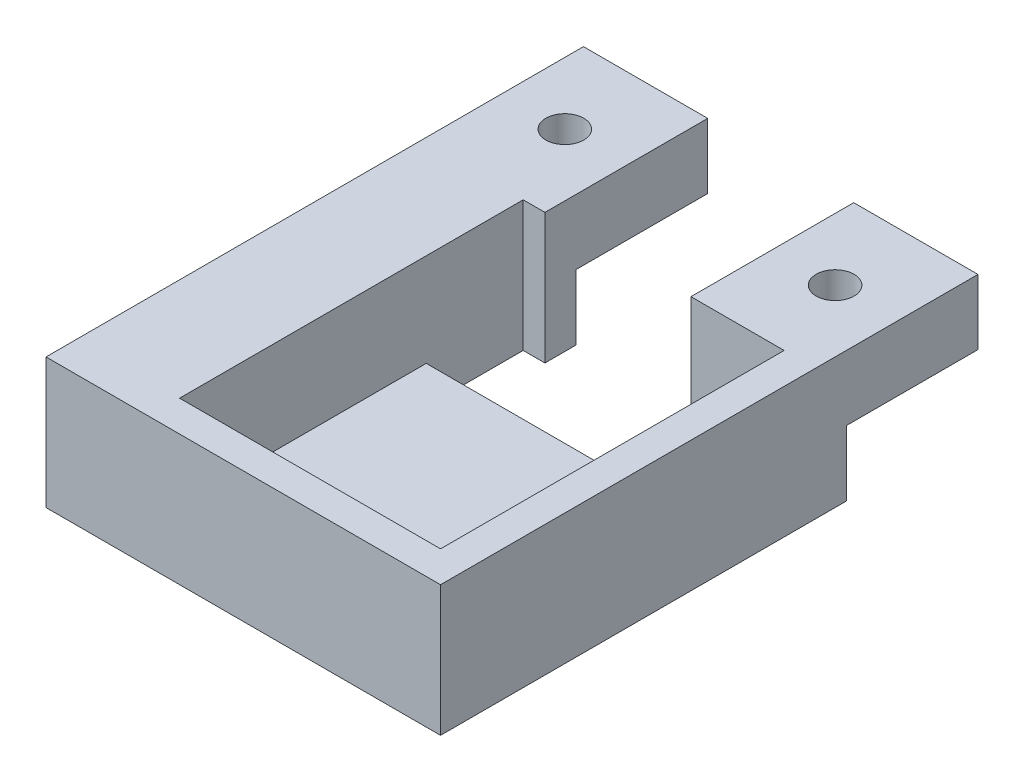
from build123d import *

# Parameters (mm, degrees)
BOSS_EXTRUDE1_DEPTH = 6
BOSS_EXTRUDE2_DEPTH = 21
BOSS_EXTRUDE3_START = 21
SKETCH1_6_W         = 20
SKETCH1_6_H         = 21.2
SKETCH1_6_R         = 3.05
BOSS_EXTRUDE3_DEPTH = 10.48


with BuildPart() as part:
    # Sketch1 → Boss-Extrude1 (new body)
    with BuildSketch(Plane(origin=(0, 0, 0), x_dir=(1, 0, 0), z_dir=(0, 1, 0))):
        Polygon((-37.5, 40.45), (-37.5, -24.85), (26, -24.85), (26, 40.45), (6, 40.45), (6, 35.45), (21, 35.45), (21, 19.85), (-21, 19.85), (-21, 35.45), (-17.5, 35.45), (-17.5, 40.45), align=None)
    extrude(amount=BOSS_EXTRUDE1_DEPTH)

    # Sketch1_5 → Boss-Extrude2 (add)
    with BuildSketch(Plane(origin=(0, 0, 0), x_dir=(1, 0, 0), z_dir=(0, 1, 0))):
        Polygon((-37.5, 40.45), (-37.5, -24.85), (26, -24.85), (26, 40.45), (6, 40.45), (6, 35.45), (21, 35.45), (21, 19.85), (21, -19.85), (-21, -19.85), (-21, 19.85), (-21, 35.45), (-17.5, 35.45), (-17.5, 40.45), align=None)
    extrude(amount=BOSS_EXTRUDE2_DEPTH)

    # Sketch1_6 → Boss-Extrude3 (add)
    with BuildSketch(Plane(origin=(0, 0, 0), x_dir=(1, 0, 0), z_dir=(0, 1, 0)).offset(BOSS_EXTRUDE3_START)):
        with Locations((-27.5, 51.05)):
            Rectangle(SKETCH1_6_W, SKETCH1_6_H)
        with Locations(Location((-27.5, 48.65, 0), (0, 0, 270))):
            Circle(SKETCH1_6_R, mode=Mode.SUBTRACT)
        with Locations((16, 51.05)):
            Rectangle(SKETCH1_6_W, SKETCH1_6_H)
        with Locations(Location((16, 48.65, 0), (0, 0, 270))):
            Circle(SKETCH1_6_R, mode=Mode.SUBTRACT)
    extrude(amount=-BOSS_EXTRUDE3_DEPTH)


solid = part.part
